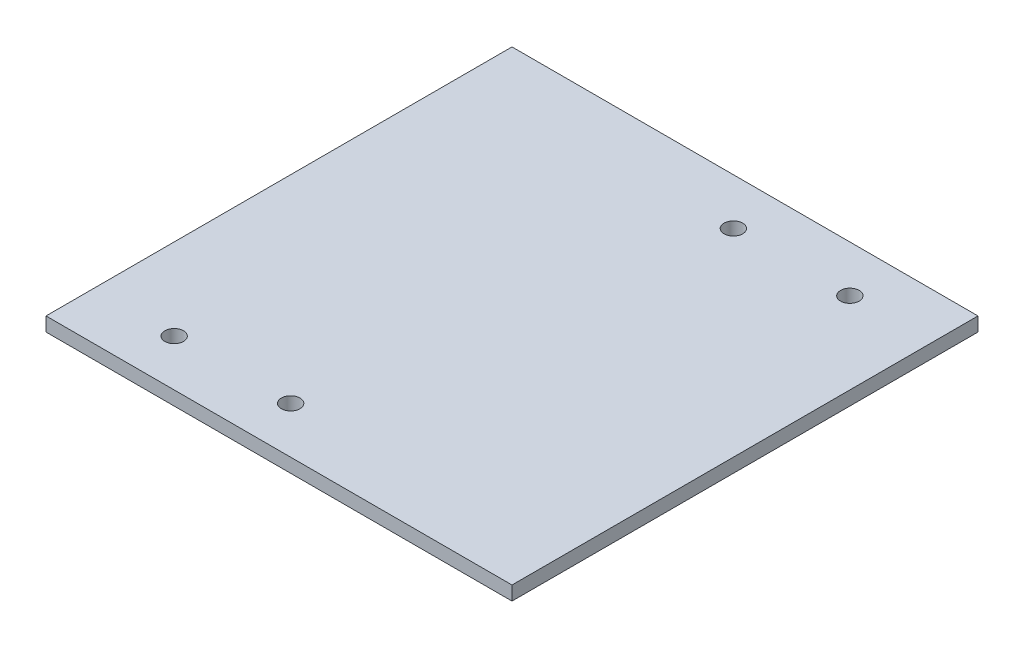
from build123d import *

# Parameters (mm, degrees)
ESQUISSE1_W        = 100
ESQUISSE1_H        = 100
ESQUISSE1_R        = 2
BOSS_EXTRU_1_DEPTH = 3


with BuildPart() as part:
    # Esquisse1 → Boss.-Extru.1 (new body)
    with BuildSketch(Plane(origin=(0, 0, 0), x_dir=(1, 0, 0), z_dir=(0, 1, 0))):
        Rectangle(ESQUISSE1_W, ESQUISSE1_H)
        with Locations((-32.5, -40)):
            Circle(ESQUISSE1_R, mode=Mode.SUBTRACT)
        with Locations((-7.5, -40)):
            Circle(ESQUISSE1_R, mode=Mode.SUBTRACT)
        with Locations((7.5, 40)):
            Circle(ESQUISSE1_R, mode=Mode.SUBTRACT)
        with Locations((32.5, 40)):
            Circle(ESQUISSE1_R, mode=Mode.SUBTRACT)
    extrude(amount=BOSS_EXTRU_1_DEPTH)


solid = part.part
